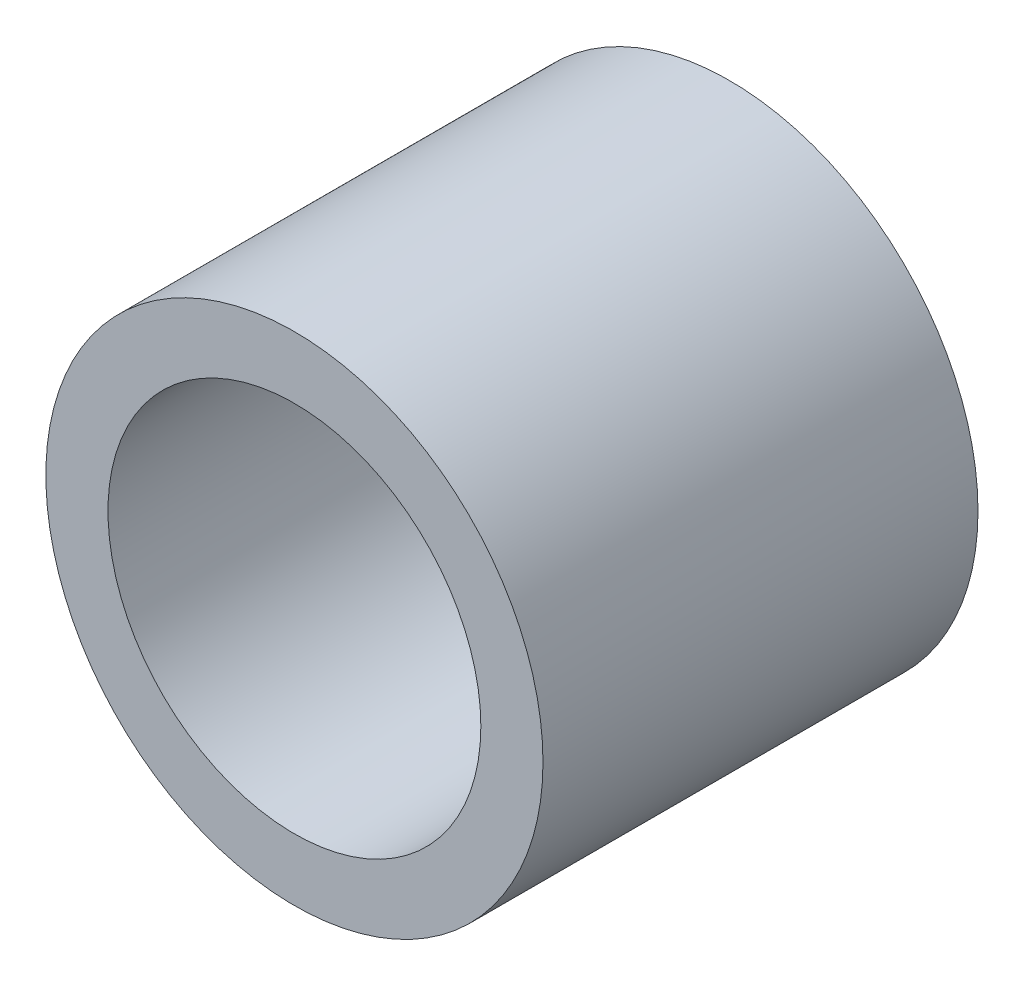
from build123d import *

# Parameters (mm, degrees)
SKETCH1_R           = 2
SKETCH1_R_2         = 1.5
BOSS_EXTRUDE1_DEPTH = 3.5


with BuildPart() as part:
    # Sketch1 → Boss-Extrude1 (new body)
    with BuildSketch(Plane.XY):
        Circle(SKETCH1_R)
        Circle(SKETCH1_R_2, mode=Mode.SUBTRACT)
    extrude(amount=BOSS_EXTRUDE1_DEPTH)


solid = part.part
